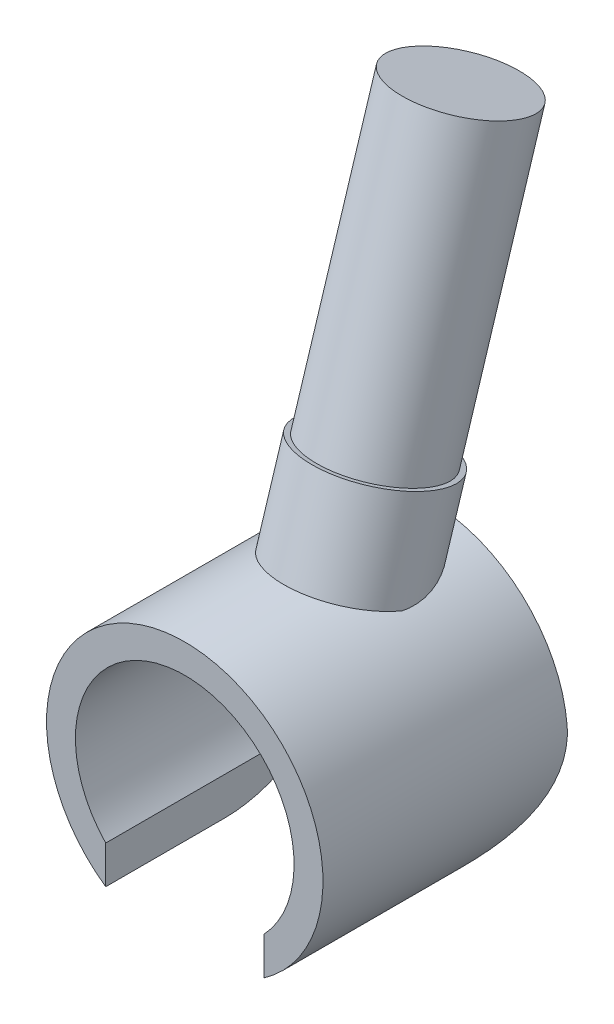
from build123d import *

# Parameters (mm, degrees)
EXTRUDE_2_DEPTH     = 2.16
CUT_EXTRUDE_1_DEPTH = 2.5
CUT_EXTRUDE_2_REACH = 5.744
SKETCH_4_R          = 1.93


with BuildPart() as part:
    # 스케치1 → 보스-돌출2 (new body, symmetric)
    with BuildSketch(Plane.XY):
        with BuildLine():
            Line((-1.395, -1.333744728), (-1.395, -2.001892854))
            ThreePointArc((-1.395, -2.001892854), (0, 2.44), (1.395, -2.001892854))
            Line((1.395, -2.001892854), (1.395, -1.333744728))
            ThreePointArc((1.395, -1.333744728), (0, 1.93), (-1.395, -1.333744728))
        make_face()
    extrude(amount=EXTRUDE_2_DEPTH, both=True)

    # 스케치2 → 컷-돌출1 (cut, symmetric)
    with BuildSketch(Plane(origin=(0, 0, 0), x_dir=(0, 0, -1), z_dir=(1, 0, 0))):
        with BuildLine():
            Line((2.16, -2.001892854), (-0.06, -2.001892854))
            ThreePointArc((-0.06, -2.001892854), (1.509777054, -1.351669909), (2.16, 0.218107146))
            Line((2.16, 0.218107146), (2.16, -2.001892854))
        make_face()
    extrude(amount=CUT_EXTRUDE_1_DEPTH, both=True, mode=Mode.SUBTRACT)

    # 스케치3 → 회전1 (revolve)
    with BuildSketch(Plane(origin=(0, 0, 0), x_dir=(0, 0, -1), z_dir=(1, 0, 0))):
        Polygon((2.712790969, 8.54), (0.705780021, 2.092266368), (-0.411350823, 2.44), (0.082869157, 4.027733632), (0.168802298, 4.000984891), (1.681593267, 8.860984891), align=None)
    revolve(axis=Axis((0, 8.54, -2.712790969), (0, -0.954812687, 0.297208232)))

    # 스케치4 → 컷-돌출2 (cut, up to next)
    with BuildSketch(Plane.XY, mode=Mode.PRIVATE) as cut_extrude_2_sk1:
        Circle(SKETCH_4_R)
    cut_extrude_2_tool1 = extrude(cut_extrude_2_sk1.sketch, amount=-CUT_EXTRUDE_2_REACH, mode=Mode.PRIVATE) & part.part
    add(cut_extrude_2_tool1.solids().sort_by_distance((0, 0, 0))[0], mode=Mode.SUBTRACT)


solid = part.part
